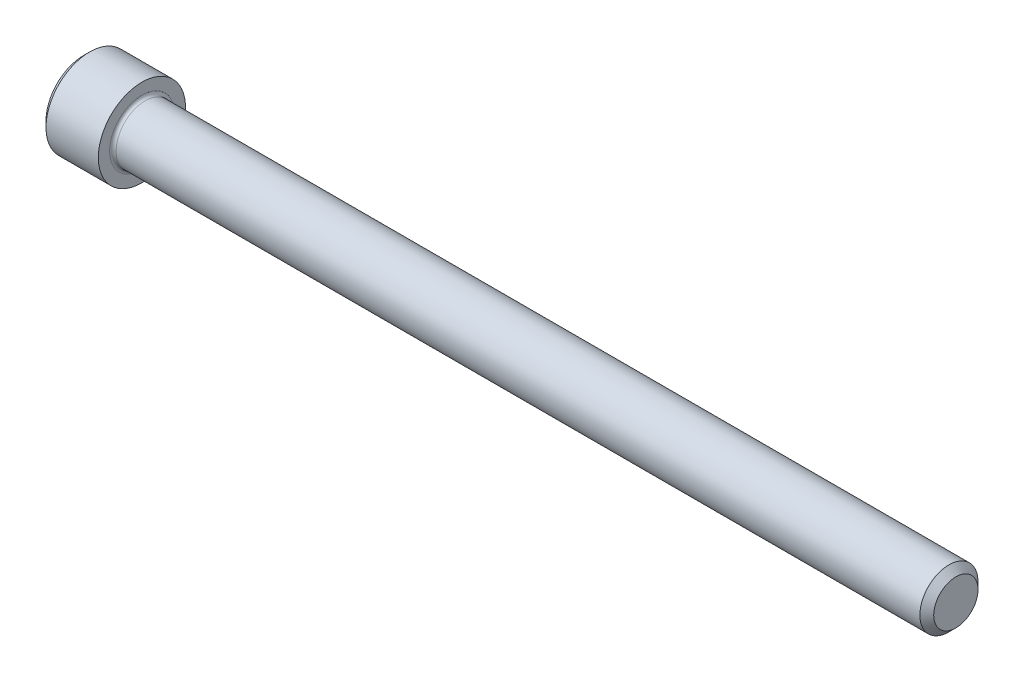
from build123d import *

# Parameters (mm, degrees)
FILLET1_R   = 0.3556
HEX_2_DEPTH = 3.048


with BuildPart() as part:
    # BodySke → Base-Revolve (revolve)
    with BuildSketch(Plane.XY):
        Polygon((0, 0), (0, 4.1275), (0.635, 4.7625), (6.35, 4.7625), (6.35, 3.175), (94.49435, 3.175), (95.25, 2.41935), (95.25, 0), align=None)
    revolve(axis=Axis((-31.75, 0, 0), (1, 0, 0)))

    # Fillet1
    fillet1_edges = [part.edges().sort_by_distance(p)[0] for p in [
        (6.35, -3.175, 0),
    ]]
    fillet(fillet1_edges, radius=FILLET1_R)

    # Sketch2 → Hex-PreBroach (revolve, cut)
    with BuildSketch(Plane.XY):
        Polygon((0, 2.38125), (3.048, 2.38125), (4.422815329, 0), (0, 0), align=None)
    revolve(axis=Axis((0, 0, 0), (1, 0, 0)), mode=Mode.SUBTRACT)

    # Sketch3 → Hex 2 (cut)
    with BuildSketch(Plane(origin=(0, 0, 0), x_dir=(0, 0.5, 0.866025404), z_dir=(-1, 0, 0))):
        Polygon((1.374815329, 2.38125), (-1.374815329, 2.38125), (-2.749630657, 0), (-1.374815329, -2.38125), (1.374815329, -2.38125), (2.749630657, 0), align=None)
    extrude(amount=-HEX_2_DEPTH, mode=Mode.SUBTRACT)


solid = part.part
